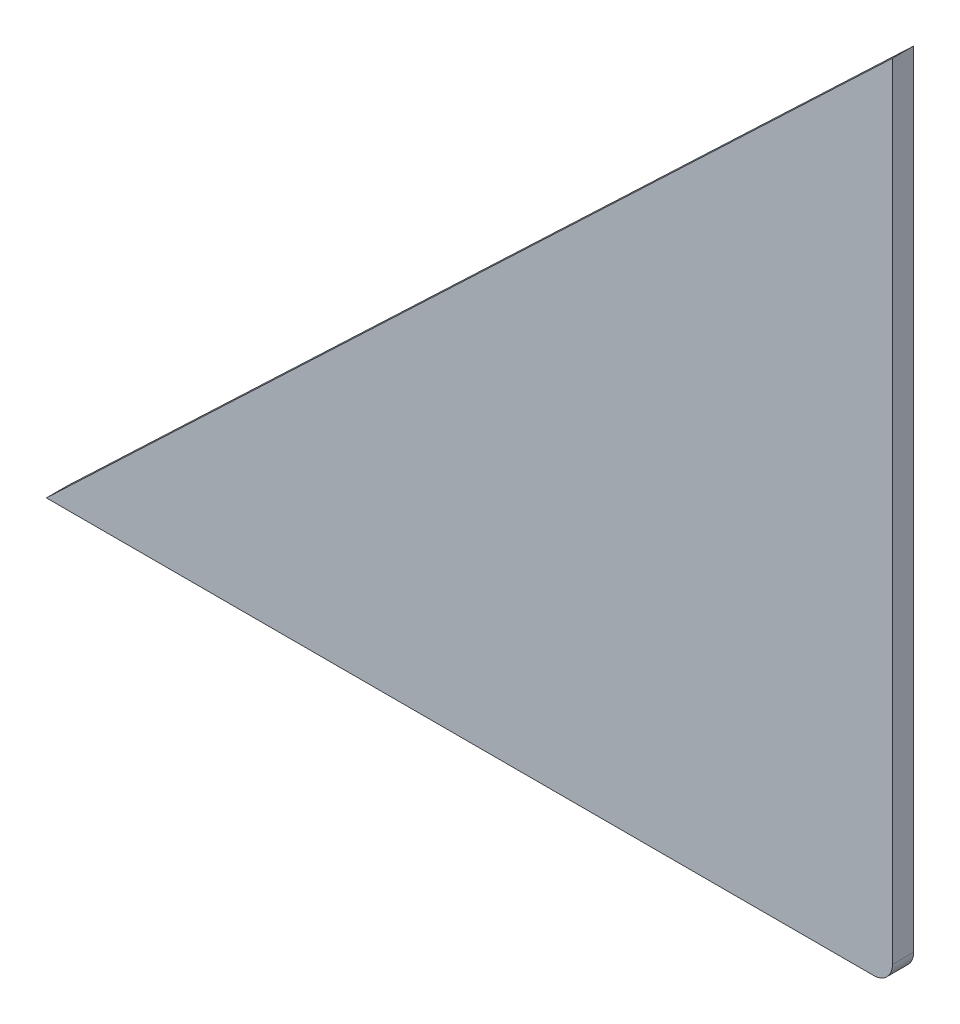
from build123d import *

# Parameters (mm, degrees)
BOSS_EXTRUDE1_DEPTH = 1


with BuildPart() as part:
    # Sketch1 → Boss-Extrude1 (new body, symmetric)
    with BuildSketch(Plane.XY):
        with BuildLine():
            Line((0, 1.8), (0, 76))
            Line((0, 76), (-80, 0))
            Line((-80, 0), (-1.8, 0))
            ThreePointArc((-1.8, 0), (-0.527207794, 0.527207794), (0, 1.8))
        make_face()
    extrude(amount=BOSS_EXTRUDE1_DEPTH, both=True)


solid = part.part
